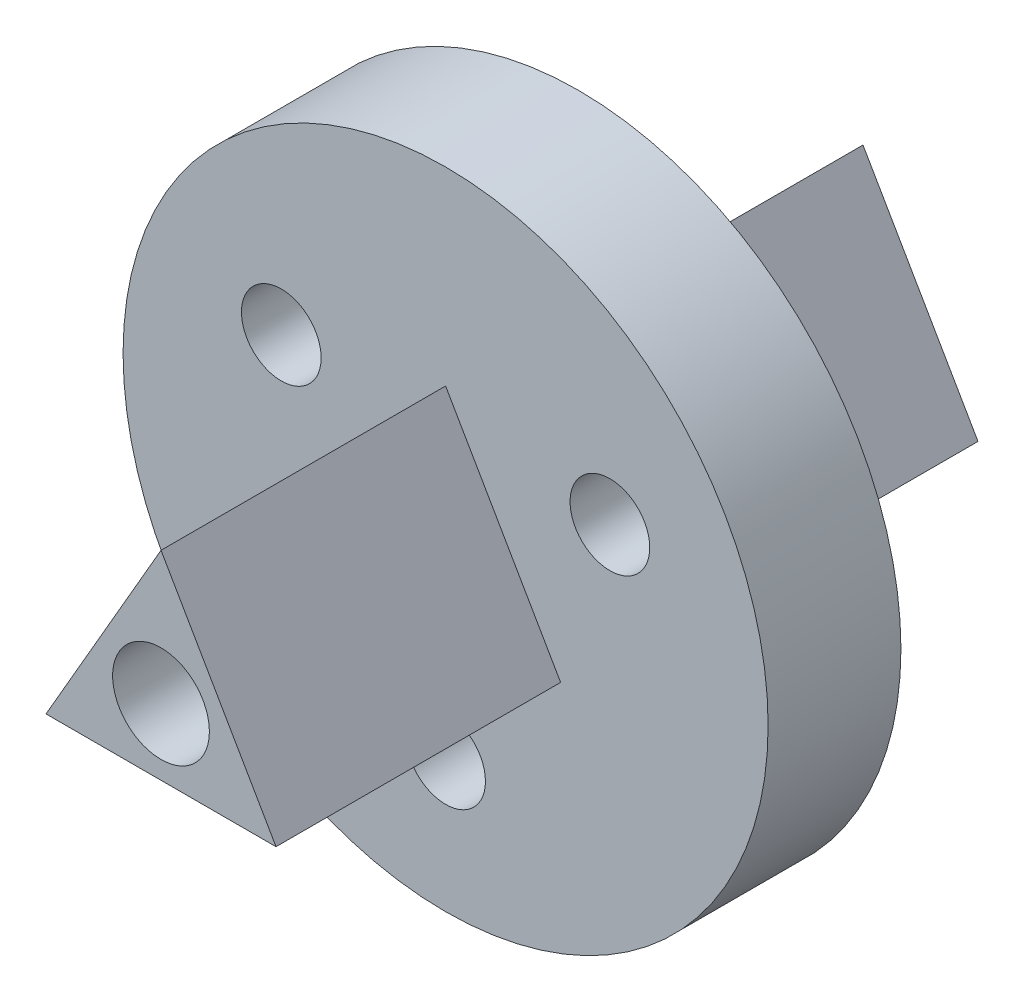
from build123d import *

# Parameters (mm, degrees)
SKETCH3_R                = 17
SKETCH3_R_2              = 2.1
BOSS_EXTRUDE1_DEPTH      = 7
SKETCH4_R                = 2.55
BOSS_EXTRUDE2_DEPTH      = 15
BOSS_EXTRUDE2_DEPTH_BACK = 22
SKETCH9_R                = 2.55
CUT_EXTRUDE1_DEPTH       = 23


with BuildPart() as part:
    # Sketch3 → Boss-Extrude1 (new body)
    with BuildSketch(Plane.XY):
        Circle(SKETCH3_R)
        with Locations((8.660254038, 5)):
            Circle(SKETCH3_R_2, mode=Mode.SUBTRACT)
        with Locations((0, -10)):
            Circle(SKETCH3_R_2, mode=Mode.SUBTRACT)
        with Locations((-8.660254038, 5)):
            Circle(SKETCH3_R_2, mode=Mode.SUBTRACT)
    extrude(amount=BOSS_EXTRUDE1_DEPTH)

    # Sketch4 → Boss-Extrude2 (add, two sides)
    with BuildSketch(Plane.XY.offset(7)) as boss_extrude2_sk:
        Polygon((0, 7), (6.062177826, -3.5), (-6.062177826, -3.5), align=None)
        Circle(SKETCH4_R, mode=Mode.SUBTRACT)
    extrude(amount=BOSS_EXTRUDE2_DEPTH)
    extrude(boss_extrude2_sk.sketch, amount=-BOSS_EXTRUDE2_DEPTH_BACK)

    # Sketch9 → Cut-Extrude1 (cut, through all)
    with BuildSketch(Plane.XY.offset(7)):
        Circle(SKETCH9_R)
    extrude(amount=-CUT_EXTRUDE1_DEPTH, mode=Mode.SUBTRACT)


solid = part.part
